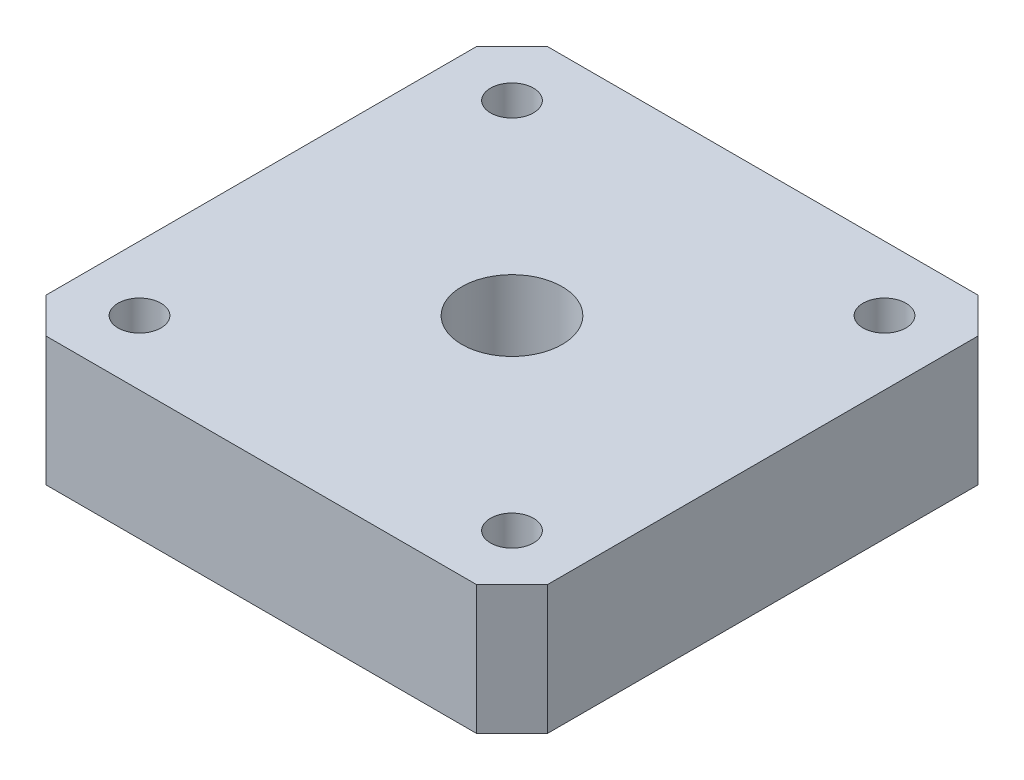
from build123d import *

# Parameters (mm, degrees)
SALIENTE_EXTRUIR1_DEPTH = 9
CROQUIS2_R              = 3.5
CORTAR_EXTRUIR1_DEPTH   = 10
CROQUIS3_R              = 1.5
CORTAR_EXTRUIR2_DEPTH   = 10


with BuildPart() as part:
    # Croquis1 → Saliente-Extruir1 (new body)
    with BuildSketch(Plane(origin=(0, 0, 0), x_dir=(1, 0, 0), z_dir=(0, 1, 0))):
        Polygon((0, 2.473088065), (2.473088065, 0), (32.526911935, 0), (35, 2.473088065), (35, 32.526911935), (32.526911935, 35), (2.473088065, 35), (0, 32.526911935), align=None)
    extrude(amount=SALIENTE_EXTRUIR1_DEPTH)

    # Croquis2 → Cortar-Extruir1 (cut, through all)
    with BuildSketch(Plane(origin=(0, 9, 0), x_dir=(1, 0, 0), z_dir=(0, 1, 0))):
        with Locations((17.5, 17.5)):
            Circle(CROQUIS2_R)
    extrude(amount=-CORTAR_EXTRUIR1_DEPTH, mode=Mode.SUBTRACT)

    # Croquis3 → Cortar-Extruir2 (cut, through all)
    with BuildSketch(Plane(origin=(0, 9, 0), x_dir=(1, 0, 0), z_dir=(0, 1, 0))):
        with Locations((4.5, 30.5)):
            Circle(CROQUIS3_R)
        with Locations((30.5, 30.5)):
            Circle(CROQUIS3_R)
        with Locations((30.5, 4.5)):
            Circle(CROQUIS3_R)
        with Locations((4.5, 4.5)):
            Circle(CROQUIS3_R)
    extrude(amount=-CORTAR_EXTRUIR2_DEPTH, mode=Mode.SUBTRACT)


solid = part.part
